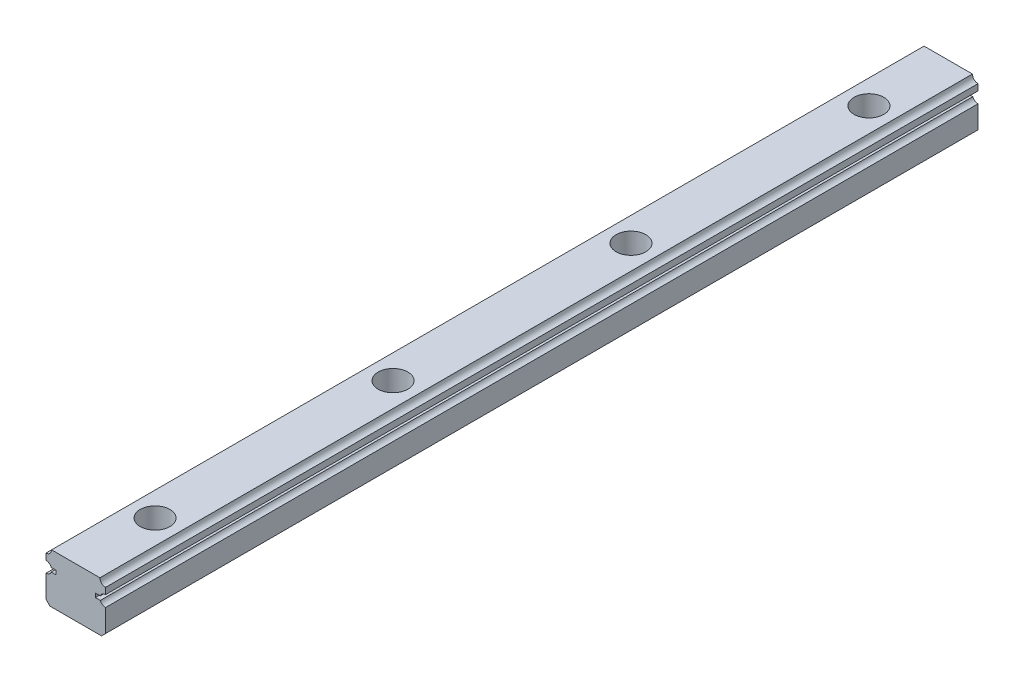
from build123d import *

# Parameters (mm, degrees)
EXTRUDE1_DEPTH  = 110
LPATTERN1_COUNT = 3
LPATTERN1_PITCH = 60


with BuildPart() as part:
    # 15mm → Extrude1 (new, symmetric)
    with BuildSketch(Plane.XY):
        with BuildLine():
            Line((4.949972, 7.600006), (6.192321846, 7.599996))
            ThreePointArc((6.192321846, 7.599996), (6.706266371, 6.946742527), (7.49999, 6.7))
            Line((7.49999, 6.7), (7.49999, 1.000024142))
            Line((7.49999, 1.000024142), (6.499965858, 0))
            Line((6.499965858, 0), (-6.499965858, 0))
            Line((-6.499965858, 0), (-7.49999, 1.000024142))
            Line((-7.49999, 1.000024142), (-7.49999, 6.7))
            ThreePointArc((-7.49999, 6.7), (-6.70626637, 6.946742527), (-6.192321846, 7.599996))
            Line((-6.192321846, 7.599996), (-4.949982, 7.599996))
            Line((-4.949982, 7.599996), (-4.949972, 8.600006))
            Line((-4.949972, 8.600006), (-6.192326435, 8.600016))
            ThreePointArc((-6.192326435, 8.600016), (-6.706271662, 9.253261115), (-7.49999, 9.5))
            Line((-7.49999, 9.5), (-7.49999, 11.099974))
            ThreePointArc((-7.49999, 11.099974), (-6.510037425, 11.510033031), (-6.099989, 12.49999))
            Line((-6.099989, 12.49999), (6.099989, 12.49999))
            ThreePointArc((6.099989, 12.49999), (6.510037425, 11.510033031), (7.49999, 11.099974))
            Line((7.49999, 11.099974), (7.49999, 9.5))
            ThreePointArc((7.49999, 9.5), (6.706271662, 9.253261115), (6.192326435, 8.600016))
            Line((6.192326435, 8.600016), (4.949982, 8.600016))
            Line((4.949982, 8.600016), (4.949972, 7.600006))
        make_face()
    extrude(amount=EXTRUDE1_DEPTH, both=True)

    # Sketch1 → Cut-Revolve1 (revolve, cut)
    with BuildSketch(Plane(origin=(0, 0, 0), x_dir=(0, 0, -1), z_dir=(1, 0, 0))):
        Polygon((-90, 12.49999), (-86.25, 12.49999), (-86.25, 7.19999), (-87.75, 7.19999), (-87.75, 0), (-90, 0), align=None)
    revolve(axis=Axis((0, 0, 90), (0, 1, 0)), mode=Mode.SUBTRACT)

    # Sketch2 → Cut-Revolve2 (revolve, cut)
    with BuildSketch(Plane(origin=(0, 0, 0), x_dir=(0, 0, -1), z_dir=(1, 0, 0))):
        Polygon((90, 0), (92.25, 0), (92.25, 7.19999), (93.75, 7.19999), (93.75, 12.49999), (90, 12.49999), align=None)
    cut_revolve2 = revolve(axis=Axis((0, 12.49999, -90), (0, -1, 0)), mode=Mode.SUBTRACT)

    # LPattern1: Cut-Revolve2 ×3
    with Locations(*[(0, 0, i * LPATTERN1_PITCH) for i in range(1, LPATTERN1_COUNT)]):
        add(cut_revolve2, mode=Mode.SUBTRACT)


solid = part.part
